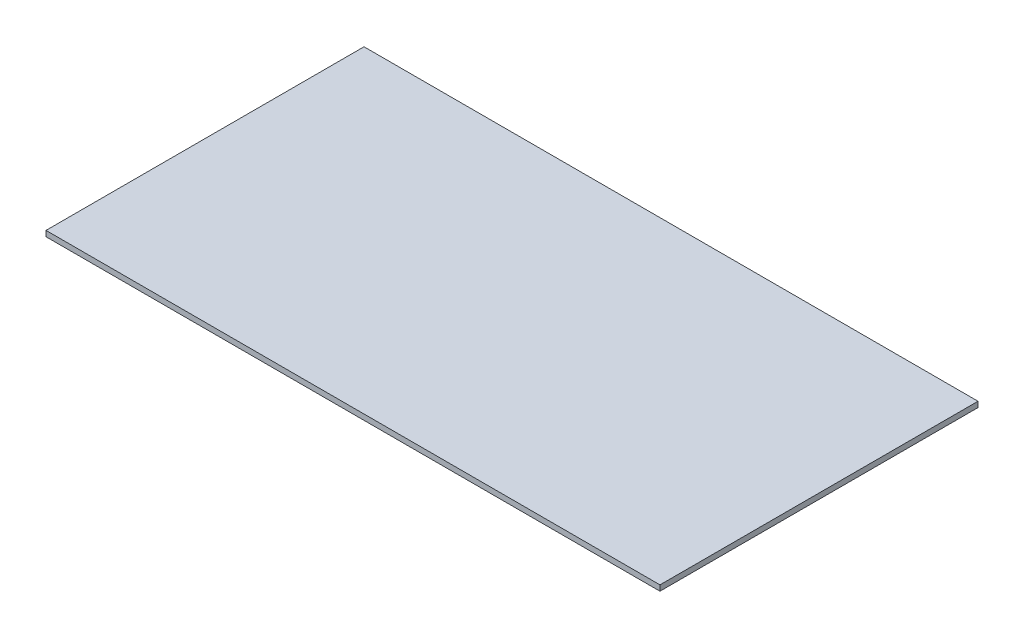
from build123d import *

# Parameters (mm, degrees)
SKETCH_1_W      = 200
SKETCH_1_H      = 103.6
EXTRUDE_1_DEPTH = 1.8


with BuildPart() as part:
    # 草图1 → 凸台-拉伸1 (new body)
    with BuildSketch(Plane(origin=(0, 0, 0), x_dir=(1, 0, 0), z_dir=(0, 1, 0))):
        with Locations((100, 51.8)):
            Rectangle(SKETCH_1_W, SKETCH_1_H)
    extrude(amount=EXTRUDE_1_DEPTH)


solid = part.part
